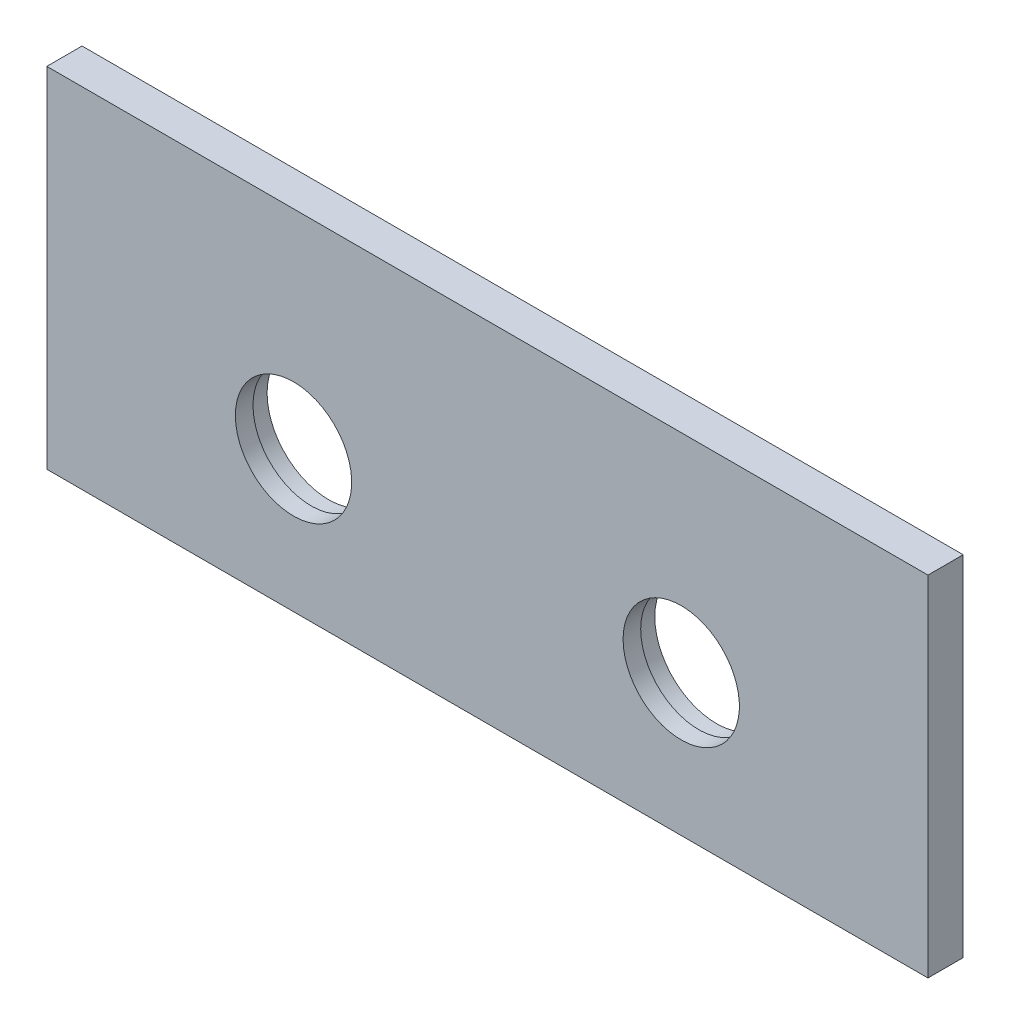
from build123d import *

# Parameters (mm, degrees)
SKETCH1_W                               = 250
SKETCH1_H                               = 99
BOSS_EXTRUDE1_DEPTH                     = 10
CBORE_FOR_M5_HEX_HEAD_BOLT1_D           = 33
CBORE_FOR_M5_HEX_HEAD_BOLT1_CBORE_D     = 35
CBORE_FOR_M5_HEX_HEAD_BOLT1_CBORE_DEPTH = 5


with BuildPart() as part:
    # Sketch1 → Boss-Extrude1 (new body)
    with BuildSketch(Plane.XY):
        Rectangle(SKETCH1_W, SKETCH1_H)
    extrude(amount=BOSS_EXTRUDE1_DEPTH)

    # CBORE for M5 Hex Head Bolt1 (through all)
    with Locations(Plane(origin=(0, 0, 0), x_dir=(-1, 0, 0), z_dir=(0, 0, -1))):
        with Locations((-55, -9.5)):
            cbore_for_m5_hex_head_bolt1 = CounterBoreHole(CBORE_FOR_M5_HEX_HEAD_BOLT1_D / 2, CBORE_FOR_M5_HEX_HEAD_BOLT1_CBORE_D / 2, CBORE_FOR_M5_HEX_HEAD_BOLT1_CBORE_DEPTH)

    # Mirror1: CBORE for M5 Hex Head Bolt1 across plane
    add(cbore_for_m5_hex_head_bolt1.mirror(Plane(origin=(0, 0, 0), x_dir=(0, 0, 1), z_dir=(1, 0, 0))), mode=Mode.SUBTRACT)


solid = part.part
